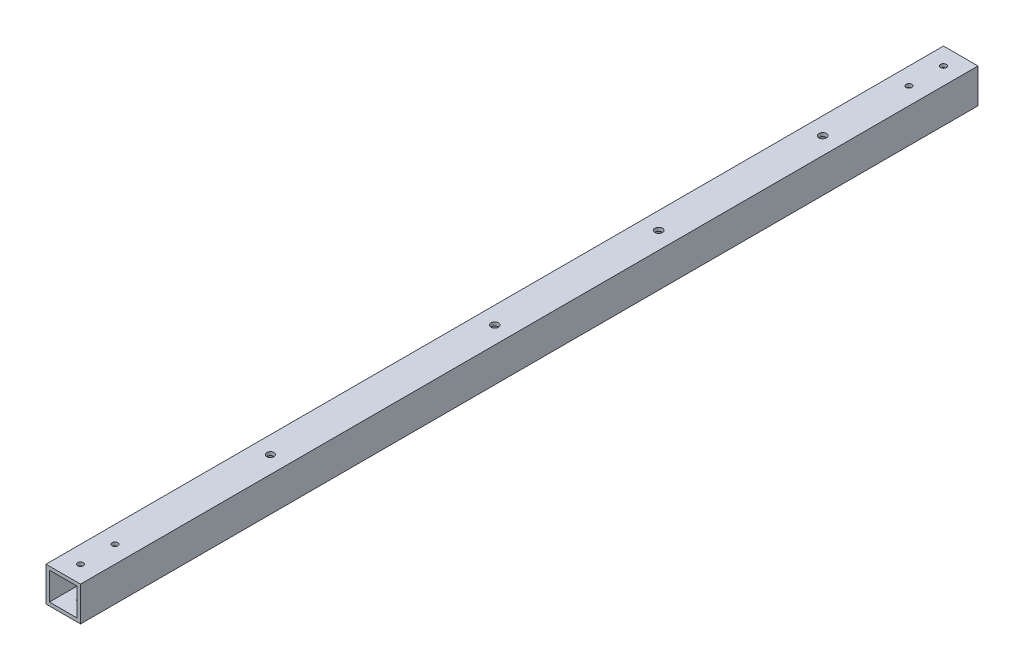
from build123d import *

# Parameters (mm, degrees)
SKETCH_1_W           = 20
SKETCH_1_H           = 20
SKETCH_1_W_2         = 16
SKETCH_1_H_2         = 16
EXTRUDE_1_DEPTH      = 560
SKETCH_4_R           = 2.2
CUT_EXTRUDE_3_DEPTH  = 560
SKETCH_5_W           = 20
SKETCH_5_H           = 20
SKETCH_5_W_2         = 16
SKETCH_5_H_2         = 16
EXTRUDE_2_DEPTH      = 20
SKETCH_6_W           = 20
SKETCH_6_H           = 20
SKETCH_6_W_2         = 16
SKETCH_6_H_2         = 16
EXTRUDE_3_DEPTH      = 20
SKETCH_8_R           = 2.2
CUT_EXTRUDE_4_DEPTH  = 20
SKETCH_9_R           = 2.2
CUT_EXTRUDE_5_DEPTH  = 20
SKETCH_10_W          = 51.42245882
SKETCH_10_H          = 30.440795882
CUT_EXTRUDE_6_DEPTH  = 40
SKETCH_11_W          = 39.362638682
SKETCH_11_H          = 52.74733359
CUT_EXTRUDE_7_DEPTH  = 40
SKETCH_12_R          = 1
CUT_EXTRUDE_8_DEPTH  = 20
SKETCH_13_R          = 1
CUT_EXTRUDE_9_DEPTH  = 20
SKETCH_15_R          = 2.2
CUT_EXTRUDE_11_DEPTH = 21
SKETCH_16_R          = 2.1
CUT_EXTRUDE_12_DEPTH = 21
M4X0_7_4_D           = 3.3
M4X0_7_5_D           = 3.3


with BuildPart() as part:
    # ｽｹｯﾁ1 → ﾎﾞｽ - 押し出し1 (new body)
    with BuildSketch(Plane.XY):
        Rectangle(SKETCH_1_W, SKETCH_1_H)
        Rectangle(SKETCH_1_W_2, SKETCH_1_H_2, mode=Mode.SUBTRACT)
    extrude(amount=EXTRUDE_1_DEPTH)

    # ｽｹｯﾁ4 → ｶｯﾄ - 押し出し3 (cut)
    with BuildSketch(Plane(origin=(0, 10, 0), x_dir=(1, 0, 0), z_dir=(0, 1, 0))):
        with Locations((0, -550)):
            Circle(SKETCH_4_R)
        with Locations((0, -10)):
            Circle(SKETCH_4_R)
    extrude(amount=-CUT_EXTRUDE_3_DEPTH, mode=Mode.SUBTRACT)

    # ｽｹｯﾁ5 → ﾎﾞｽ - 押し出し2 (add)
    with BuildSketch(Plane(origin=(0, 0, 0), x_dir=(-1, 0, 0), z_dir=(0, 0, -1))):
        Rectangle(SKETCH_5_W, SKETCH_5_H)
        Rectangle(SKETCH_5_W_2, SKETCH_5_H_2, mode=Mode.SUBTRACT)
    extrude(amount=EXTRUDE_2_DEPTH)

    # ｽｹｯﾁ6 → ﾎﾞｽ - 押し出し3 (add)
    with BuildSketch(Plane.XY.offset(560)):
        Rectangle(SKETCH_6_W, SKETCH_6_H)
        Rectangle(SKETCH_6_W_2, SKETCH_6_H_2, mode=Mode.SUBTRACT)
    extrude(amount=EXTRUDE_3_DEPTH)

    # ｽｹｯﾁ8 → ｶｯﾄ - 押し出し4 (cut)
    with BuildSketch(Plane(origin=(10, 0, 0), x_dir=(0, 0, -1), z_dir=(1, 0, 0))):
        with Locations((-570, 0)):
            Circle(SKETCH_8_R)
    extrude(amount=-CUT_EXTRUDE_4_DEPTH, mode=Mode.SUBTRACT)

    # ｽｹｯﾁ9 → ｶｯﾄ - 押し出し5 (cut)
    with BuildSketch(Plane(origin=(10, 0, 0), x_dir=(0, 0, -1), z_dir=(1, 0, 0))):
        with Locations((10, 0)):
            Circle(SKETCH_9_R)
    extrude(amount=-CUT_EXTRUDE_5_DEPTH, mode=Mode.SUBTRACT)

    # ｽｹｯﾁ10 → ｶｯﾄ - 押し出し6 (cut)
    with BuildSketch(Plane(origin=(0, 0, -20), x_dir=(-1, 0, 0), z_dir=(0, 0, -1))):
        Rectangle(SKETCH_10_W, SKETCH_10_H)
    extrude(amount=-CUT_EXTRUDE_6_DEPTH, mode=Mode.SUBTRACT)

    # ｽｹｯﾁ11 → ｶｯﾄ - 押し出し7 (cut)
    with BuildSketch(Plane.XY.offset(580)):
        Rectangle(SKETCH_11_W, SKETCH_11_H)
    extrude(amount=-CUT_EXTRUDE_7_DEPTH, mode=Mode.SUBTRACT)

    # ｽｹｯﾁ12 → ｶｯﾄ - 押し出し8 (cut)
    with BuildSketch(Plane(origin=(0, -10, 0), x_dir=(-1, 0, 0), z_dir=(0, -1, 0))):
        with Locations((0, -530)):
            Circle(SKETCH_12_R)
        with Locations((0, -510)):
            Circle(SKETCH_12_R)
    extrude(amount=-CUT_EXTRUDE_8_DEPTH, mode=Mode.SUBTRACT)

    # ｽｹｯﾁ13 → ｶｯﾄ - 押し出し9 (cut)
    with BuildSketch(Plane(origin=(0, -10, 0), x_dir=(-1, 0, 0), z_dir=(0, -1, 0))):
        with Locations((0, -30)):
            Circle(SKETCH_13_R)
        with Locations((0, -50)):
            Circle(SKETCH_13_R)
    extrude(amount=-CUT_EXTRUDE_9_DEPTH, mode=Mode.SUBTRACT)

    # ｽｹｯﾁ15 → ｶｯﾄ - 押し出し11 (cut, through all)
    with BuildSketch(Plane.XZ.offset(10)):
        with Locations((0, 100)):
            Circle(SKETCH_15_R)
        with Locations((0, 195)):
            Circle(SKETCH_15_R)
        with Locations((0, 290)):
            Circle(SKETCH_15_R)
    extrude(amount=-CUT_EXTRUDE_11_DEPTH, mode=Mode.SUBTRACT)

    # ｽｹｯﾁ16 → ｶｯﾄ - 押し出し12 (cut, through all)
    with BuildSketch(Plane.XZ.offset(10)):
        with Locations((0, 420)):
            Circle(SKETCH_16_R)
    extrude(amount=-CUT_EXTRUDE_12_DEPTH, mode=Mode.SUBTRACT)

    # M4x0.7 ねじ穴4 (through all)
    with Locations(Plane(origin=(0, -10, 30), x_dir=(0, 0, -1), z_dir=(0, -1, 0))):
        with Locations((0, 0), (-20, 0)):
            Hole(M4X0_7_4_D / 2)

    # M4x0.7 ねじ穴5 (through all)
    with Locations(Plane(origin=(0, -10, 530), x_dir=(0, 0, -1), z_dir=(0, -1, 0))):
        with Locations((0, 0), (20, 0)):
            Hole(M4X0_7_5_D / 2)


solid = part.part
